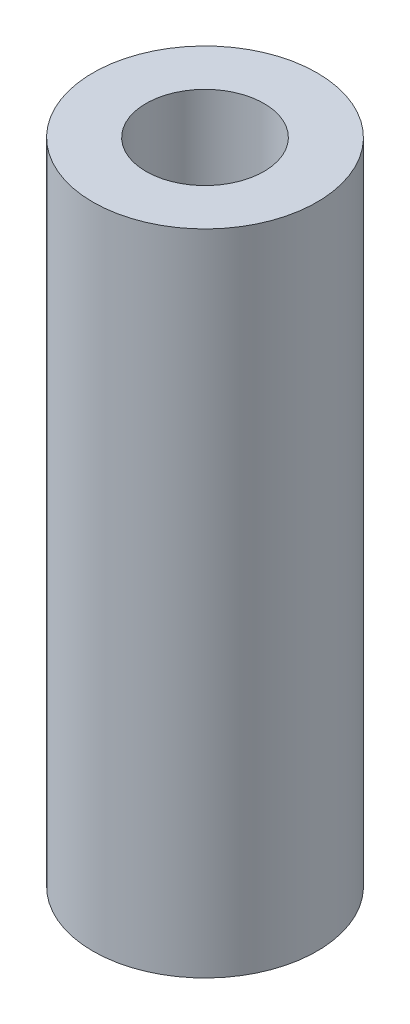
from build123d import *

# Parameters (mm, degrees)
SKETCH1_R           = 9.5
SKETCH1_R_2         = 5
BOSS_EXTRUDE1_DEPTH = 55


with BuildPart() as part:
    # Sketch1 → Boss-Extrude1 (new body)
    with BuildSketch(Plane(origin=(0, 0, 0), x_dir=(1, 0, 0), z_dir=(0, 1, 0))):
        Circle(SKETCH1_R)
        Circle(SKETCH1_R_2, mode=Mode.SUBTRACT)
    extrude(amount=BOSS_EXTRUDE1_DEPTH)


solid = part.part
